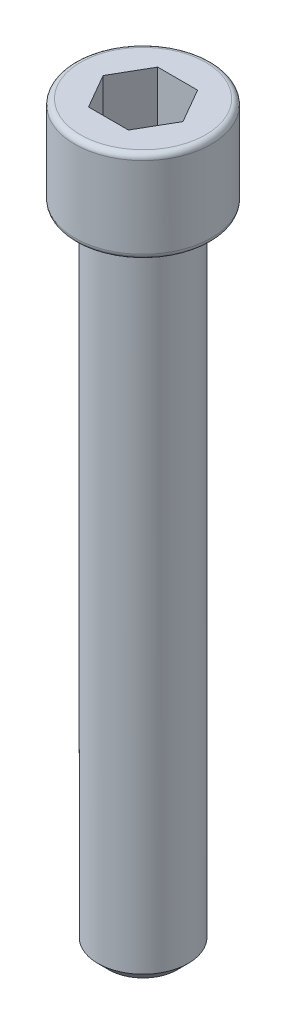
from build123d import *

# Parameters (mm, degrees)
EXTRUDE1_DEPTH = 3.81
FILLET1_R      = 0.381
CHAMFER1_SIZE  = 0.762


with BuildPart() as part:
    # Sketch1 → Revolve1 (revolve)
    with BuildSketch(Plane.XY):
        Polygon((0, 0), (0, 50.8), (-4.699, 50.8), (-4.699, 44.45), (-3.1115, 44.45), (-3.1115, 0), align=None)
    revolve(axis=Axis((0, 0, 0), (0, 1, 0)))

    # Sketch2 → Extrude1 (cut)
    with BuildSketch(Plane(origin=(0, 50.8, 0), x_dir=(1, 0, 0), z_dir=(0, 1, 0))):
        Polygon((2.7496262, 0), (1.3748131, 2.38124614), (-1.3748131, 2.38124614), (-2.7496262, 0), (-1.3748131, -2.38124614), (1.3748131, -2.38124614), align=None)
    extrude(amount=-EXTRUDE1_DEPTH, mode=Mode.SUBTRACT)

    # Fillet1
    fillet1_edges = [part.edges().sort_by_distance(p)[0] for p in [
        (4.699, 44.45, 0),
        (4.699, 50.8, 0),
    ]]
    fillet(fillet1_edges, radius=FILLET1_R)

    # Chamfer1
    chamfer1_edges = [part.edges().sort_by_distance(p)[0] for p in [
        (3.1115, 0, 0),
    ]]
    chamfer(chamfer1_edges, length=CHAMFER1_SIZE)


solid = part.part
